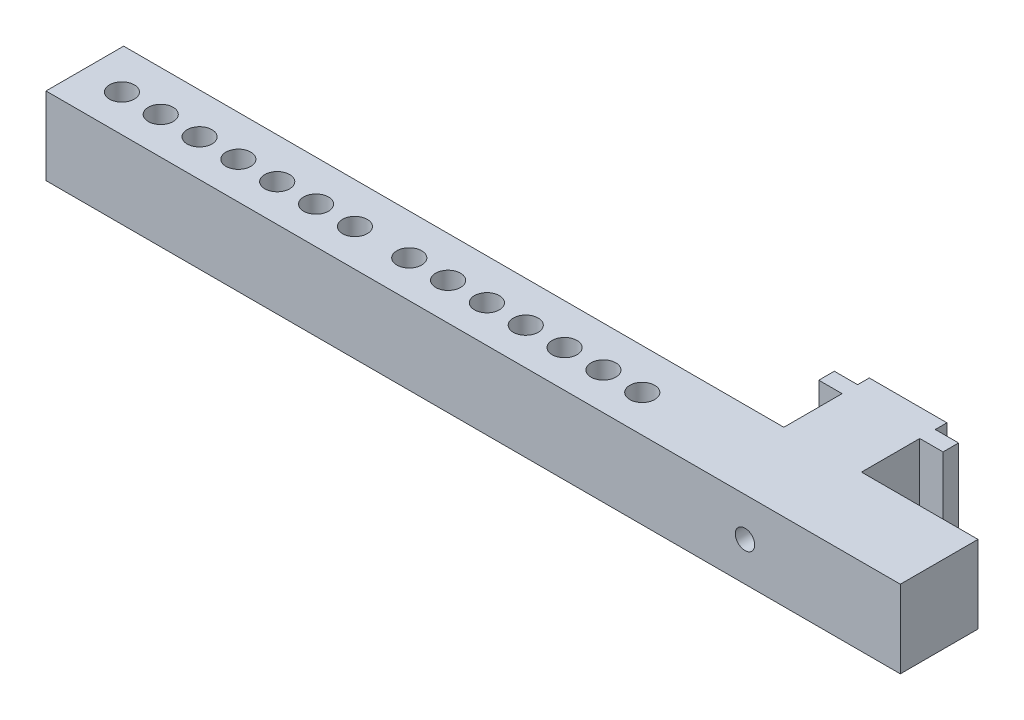
from build123d import *

# Parameters (mm, degrees)
SKETCH1_W                  = 10
SKETCH1_H                  = 10
BOSS_EXTRUDE1_DEPTH        = 11
SKETCH2_W                  = 2
SKETCH2_H                  = 10
BOSS_EXTRUDE2_DEPTH        = 3
BOSS_EXTRUDE2_DEPTH_BACK   = 13
SKETCH3_W                  = 40
SKETCH3_H                  = 10
BOSS_EXTRUDE3_DEPTH        = 10
SKETCH5_W                  = 10
SKETCH5_H                  = 10
BOSS_EXTRUDE4_DEPTH        = 70
F_2_5MM_DOWEL_SLOT1_D      = 2.5
F_3_2_3_2_DIAMETER_SLOT2_D = 3.2


with BuildPart() as part:
    # Sketch1 → Boss-Extrude1 (new body)
    with BuildSketch(Plane.XY):
        Rectangle(SKETCH1_W, SKETCH1_H)
    extrude(amount=BOSS_EXTRUDE1_DEPTH)

    # Sketch2 → Boss-Extrude2 (add, two sides)
    with BuildSketch(Plane(origin=(5, 0, 0), x_dir=(0, 0, -1), z_dir=(1, 0, 0))) as boss_extrude2_sk:
        with Locations((-2.5, 0)):
            Rectangle(SKETCH2_W, SKETCH2_H)
    extrude(amount=BOSS_EXTRUDE2_DEPTH)
    extrude(boss_extrude2_sk.sketch, amount=-BOSS_EXTRUDE2_DEPTH_BACK)

    # Sketch3 → Boss-Extrude3 (add)
    with BuildSketch(Plane.XY.offset(11)):
        Rectangle(SKETCH3_W, SKETCH3_H)
    extrude(amount=BOSS_EXTRUDE3_DEPTH)

    # Sketch5 → Boss-Extrude4 (add)
    with BuildSketch(Plane.ZY.offset(20)):
        with Locations((16, 0)):
            Rectangle(SKETCH5_W, SKETCH5_H)
    extrude(amount=BOSS_EXTRUDE4_DEPTH)

    # Ø2.5mm Dowel Slot1 (through all)
    with Locations(Plane.XY.offset(21)):
        with Locations((0, 0)):
            Hole(F_2_5MM_DOWEL_SLOT1_D / 2)

    # Ø3.2 (3.2) Diameter Slot2 (through all)
    with Locations(Plane(origin=(0, -5, 0), x_dir=(-1, 0, 0), z_dir=(0, -1, 0))):
        with Locations((85, -16.229165357), (80, -16.229165357), (48, -16.229165357), (43, -16.229165357), (75, -16.229165357), (70, -16.229165357), (65, -16.229165357), (60, -16.229165357), (38, -16.229165357), (33, -16.229165357), (28, -16.229165357), (23, -16.229165357), (55, -16.229165357), (18, -16.229165357)):
            Hole(F_3_2_3_2_DIAMETER_SLOT2_D / 2)


solid = part.part
